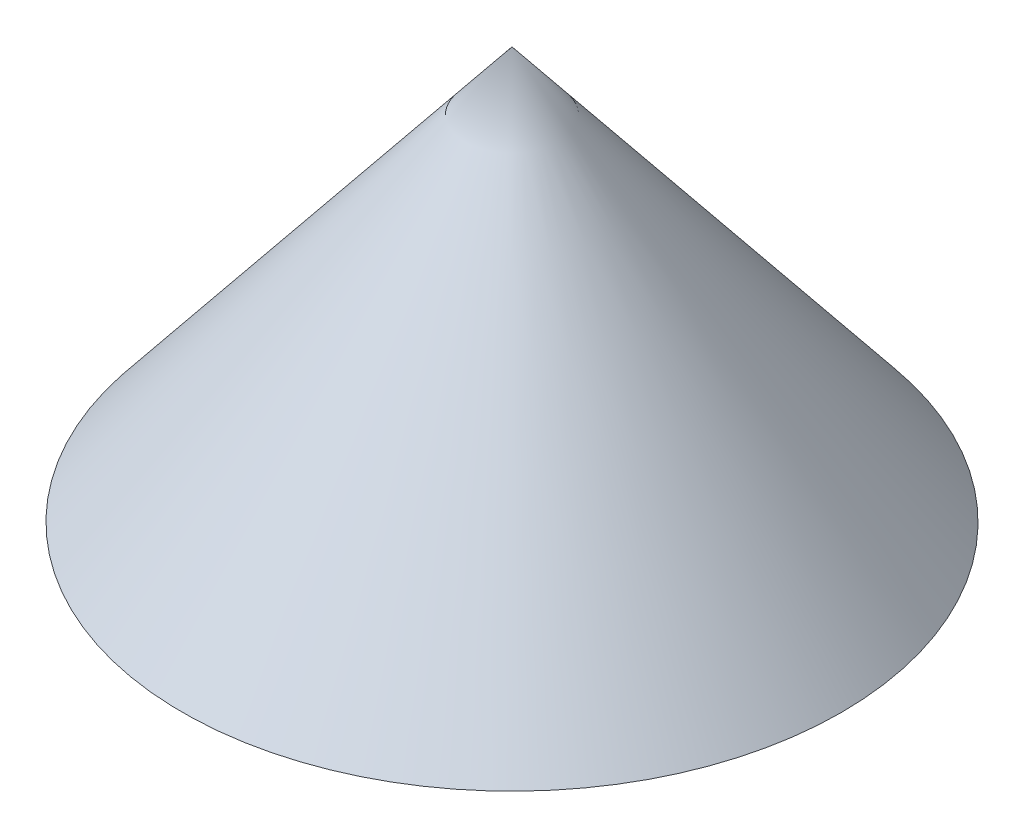
from build123d import *


with BuildPart() as part:
    # Sketch1 → Revolve1 (revolve)
    with BuildSketch(Plane.XY):
        Polygon((0, 0), (25, 0), (0, 31.224989992), align=None)
    revolve(axis=Axis((0, 0, 0), (0, 1, 0)))


solid = part.part
